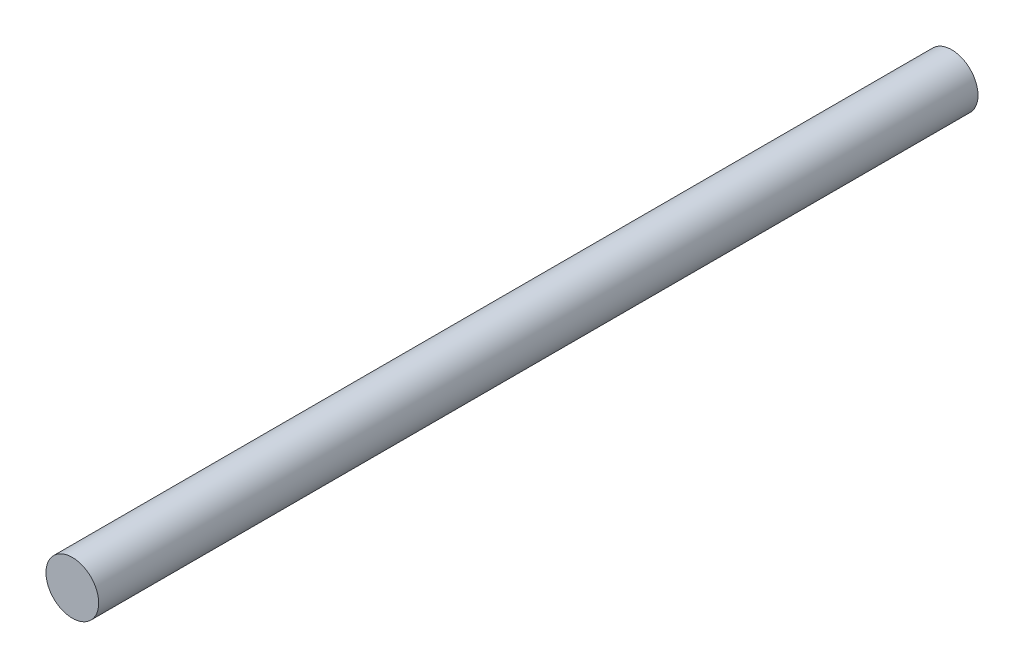
from build123d import *

# Parameters (mm, degrees)
ESQUISSE1_R        = 30
BOSS_EXTRU_2_DEPTH = 1000


with BuildPart() as part:
    # Esquisse1 → Boss.-Extru.2 (new body)
    with BuildSketch(Plane.XY):
        Circle(ESQUISSE1_R)
    extrude(amount=BOSS_EXTRU_2_DEPTH)


solid = part.part
